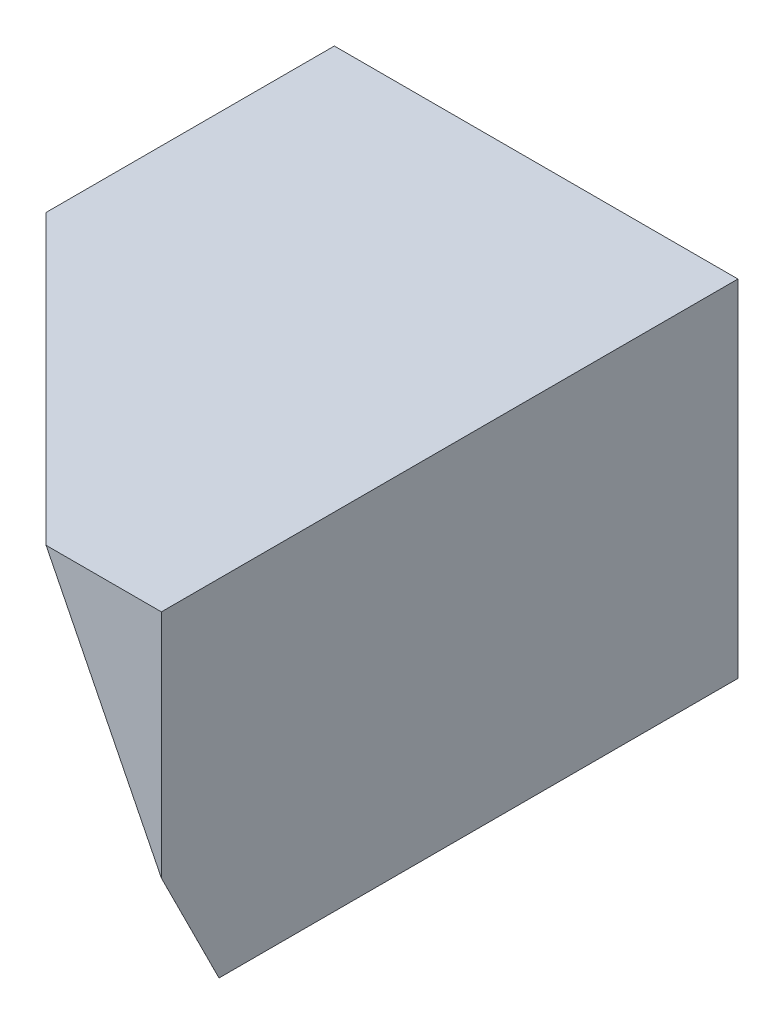
from build123d import *

# Parameters (mm, degrees)
BOSS_EXTRUDE1_DEPTH = 5
CUT_EXTRUDE1_DEPTH  = 8
CUT_EXTRUDE5_DEPTH  = 3
CUT_EXTRUDE6_DEPTH  = 5
CUT_EXTRUDE7_DEPTH  = 10
CUT_EXTRUDE10_DEPTH = 1


with BuildPart() as part:
    # Sketch1 → Boss-Extrude1 (new body, symmetric)
    with BuildSketch(Plane.XY):
        Polygon((7, -6), (7, 0), (0, 0), (0, -2), (0, -4), (2, -4), (2, -2), (5, -2), (5, -6), align=None)
        Polygon((4, -6), (5, -6), (5, -2), (2, -2), (2, -4), (0, -4), (0, -2), (-1, -2), (-1, -5), (2, -7), (4, -7), align=None)
    extrude(amount=BOSS_EXTRUDE1_DEPTH, both=True)

    # Sketch2 → Cut-Extrude1 (cut)
    with BuildSketch(Plane.XY.offset(5)):
        Polygon((5, -6), (5, -2), (2, -2), (2, -4), (0, -4), (0, -2), (-1, -2), (-1, -5), (2, -7), (4, -7), (4, -6), align=None)
    extrude(amount=-CUT_EXTRUDE1_DEPTH, mode=Mode.SUBTRACT)

    # Sketch4 → Cut-Extrude5 (cut, through all)
    with BuildSketch(Plane.XZ.offset(2)):
        Polygon((5, 5), (0, 0), (0, 5), align=None)
    extrude(amount=-CUT_EXTRUDE5_DEPTH, mode=Mode.SUBTRACT)

    # Sketch5 → Cut-Extrude6 (cut, through all)
    with BuildSketch(Plane.XZ.offset(4)):
        Polygon((2, 2), (0, 0), (0, 5), (2, 5), align=None)
    extrude(amount=-CUT_EXTRUDE6_DEPTH, mode=Mode.SUBTRACT)

    # Sketch9 → Cut-Extrude7 (cut)
    with BuildSketch(Plane(origin=(0, 0, 0), x_dir=(0.596284794, 0.298142397, 0.745355992), z_dir=(-0.666666667, -0.333333333, 0.666666667))):
        Polygon((0, 0), (-2.683281573, -3.577708764), (4.829366967, -9.212195169), (9.390810676, -3.130270225), align=None)
    extrude(amount=CUT_EXTRUDE7_DEPTH, mode=Mode.SUBTRACT)

    # Sketch10 → Cut-Extrude10 (cut)
    with BuildSketch(Plane(origin=(7, 0, 0), x_dir=(0, 0, -1), z_dir=(1, 0, 0))):
        Polygon((-4, -6), (-5, -6), (-5, -3.998994023), align=None)
    extrude(amount=-CUT_EXTRUDE10_DEPTH, mode=Mode.SUBTRACT)


solid = part.part
